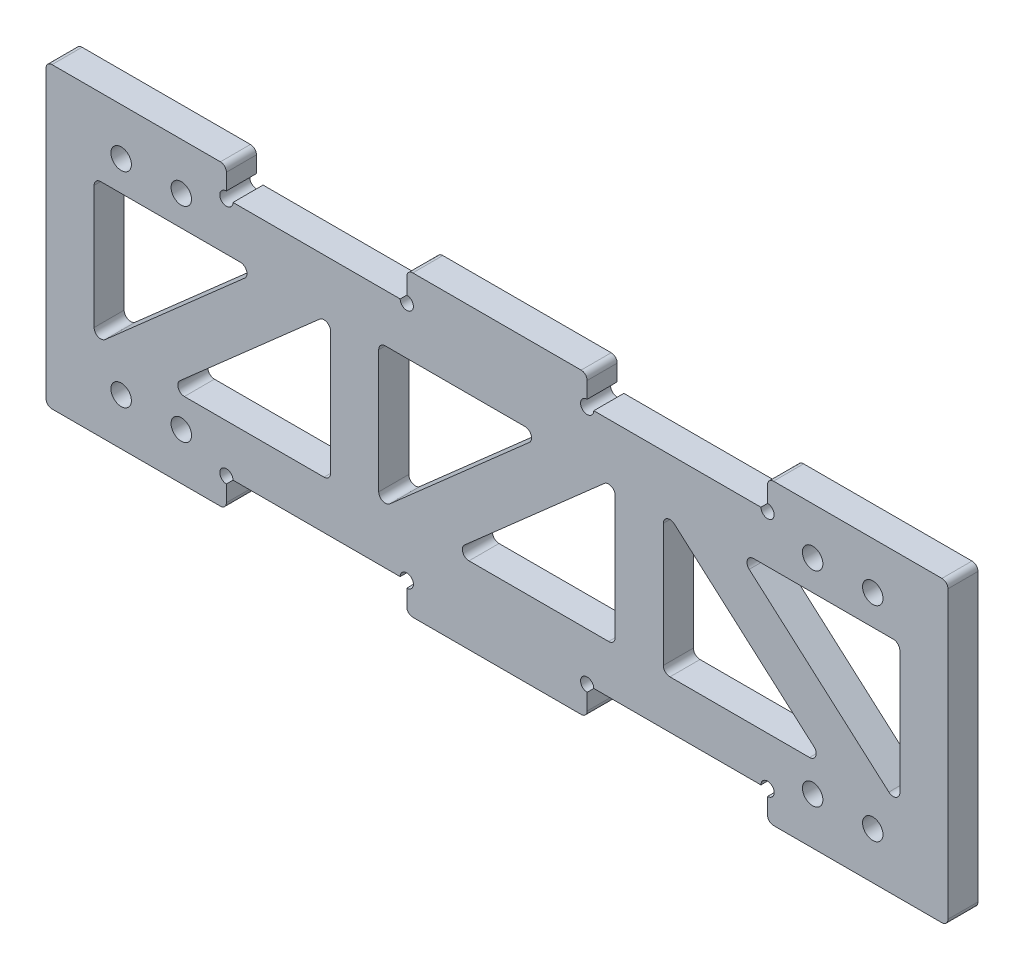
from build123d import *

# Parameters (mm, degrees)
SKETCH_1_W          = 150
SKETCH_1_H          = 40
EXTRUDE_1_DEPTH     = 5
SKETCH_2_W          = 30
SKETCH_2_H          = 4.8
EXTRUDE_2_DEPTH     = 5
SKETCH_3_R          = 1.1
CUT_EXTRUDE_1_DEPTH = 5
FILLET_1_R          = 1
CUT_EXTRUDE_2_DEPTH = 10
FILLET_2_R          = 1.1
HOLE_WIZARD_M3_1_D  = 3.4


with BuildPart() as part:
    # 草图1 → 凸台-拉伸1 (new body)
    with BuildSketch(Plane.XY):
        with Locations((75, 20)):
            Rectangle(SKETCH_1_W, SKETCH_1_H)
    extrude(amount=EXTRUDE_1_DEPTH)

    # 草图2 → 凸台-拉伸2 (add)
    with BuildSketch(Plane.XY.offset(5)):
        with Locations((15, 42.4)):
            Rectangle(SKETCH_2_W, SKETCH_2_H)
        with Locations((75, 42.4)):
            Rectangle(SKETCH_2_W, SKETCH_2_H)
        with Locations((135, 42.4)):
            Rectangle(SKETCH_2_W, SKETCH_2_H)
        with Locations((15, -2.4)):
            Rectangle(SKETCH_2_W, SKETCH_2_H)
        with Locations((75, -2.4)):
            Rectangle(SKETCH_2_W, SKETCH_2_H)
        with Locations((135, -2.4)):
            Rectangle(SKETCH_2_W, SKETCH_2_H)
    extrude(amount=-EXTRUDE_2_DEPTH)

    # 草图3 → 切除-拉伸1 (cut)
    with BuildSketch(Plane.XY.offset(5)):
        with Locations((30, 40)):
            Circle(SKETCH_3_R)
        with Locations((60, 40)):
            Circle(SKETCH_3_R)
        with Locations((90, 40)):
            Circle(SKETCH_3_R)
        with Locations((120, 40)):
            Circle(SKETCH_3_R)
        with Locations((30, 0)):
            Circle(SKETCH_3_R)
        with Locations((60, 0)):
            Circle(SKETCH_3_R)
        with Locations((90, 0)):
            Circle(SKETCH_3_R)
        with Locations((120, 0)):
            Circle(SKETCH_3_R)
    extrude(amount=-CUT_EXTRUDE_1_DEPTH, mode=Mode.SUBTRACT)

    # 圆角1
    fillet_1_edges = [part.edges().sort_by_distance(p)[0] for p in [
        (0, 44.8, 2.5),
        (30, 44.8, 2.5),
        (60, 44.8, 2.5),
        (90, 44.8, 2.5),
        (150, 44.8, 2.5),
        (120, 44.8, 2.5),
        (0, -4.8, 2.5),
        (30, -4.8, 2.5),
        (60, -4.8, 2.5),
        (90, -4.8, 2.5),
        (120, -4.8, 2.5),
        (150, -4.8, 2.5),
    ]]
    fillet(fillet_1_edges, radius=FILLET_1_R)

    # 草图5 → 切除-拉伸2 (cut)
    with BuildSketch(Plane(origin=(0, 0, 0), x_dir=(-1, 0, 0), z_dir=(0, 0, -1))):
        Polygon((-114.766536075, 32), (-118.9, 32), (-142, 32), (-142, 8), align=None)
        Polygon((-102.666666667, 8), (-102.666666667, 32), (-129.900130591, 8), align=None)
        Polygon((-67.433202742, 8), (-94.666666667, 32), (-94.666666667, 8), align=None)
        Polygon((-8, 32), (-35.233463925, 32), (-8, 8), align=None)
        Polygon((-55.333333333, 32), (-82.566797258, 32), (-55.333333333, 8), align=None)
        Polygon((-20.099869409, 8), (-47.333333333, 32), (-47.333333333, 8), align=None)
    extrude(amount=-CUT_EXTRUDE_2_DEPTH, mode=Mode.SUBTRACT)

    # 圆角2
    fillet_2_edges = [part.edges().sort_by_distance(p)[0] for p in [
        (55.333333333, 8, 2.5),
        (82.566797258, 32, 2.5),
        (55.333333333, 32, 2.5),
        (8, 8, 2.5),
        (35.233463925, 32, 2.5),
        (8, 32, 2.5),
        (94.666666667, 32, 2.5),
        (67.433202742, 8, 2.5),
        (94.666666667, 8, 2.5),
        (102.666666667, 32, 2.5),
        (102.666666667, 8, 2.5),
        (129.900130591, 8, 2.5),
        (47.333333333, 32, 2.5),
        (20.099869409, 8, 2.5),
        (47.333333333, 8, 2.5),
        (142, 8, 2.5),
        (142, 32, 2.5),
        (114.766536075, 32, 2.5),
    ]]
    fillet(fillet_2_edges, radius=FILLET_2_R)

    # M3 间隙孔1 (through all)
    with Locations(Plane(origin=(0, 0, 0), x_dir=(-1, 0, 0), z_dir=(0, 0, -1))):
        with Locations((-137.5, 37), (-127.5, 37), (-22.5, 37), (-12.5, 37), (-137.5, 3), (-127.5, 3), (-22.5, 3), (-12.5, 3)):
            Hole(HOLE_WIZARD_M3_1_D / 2)


solid = part.part
